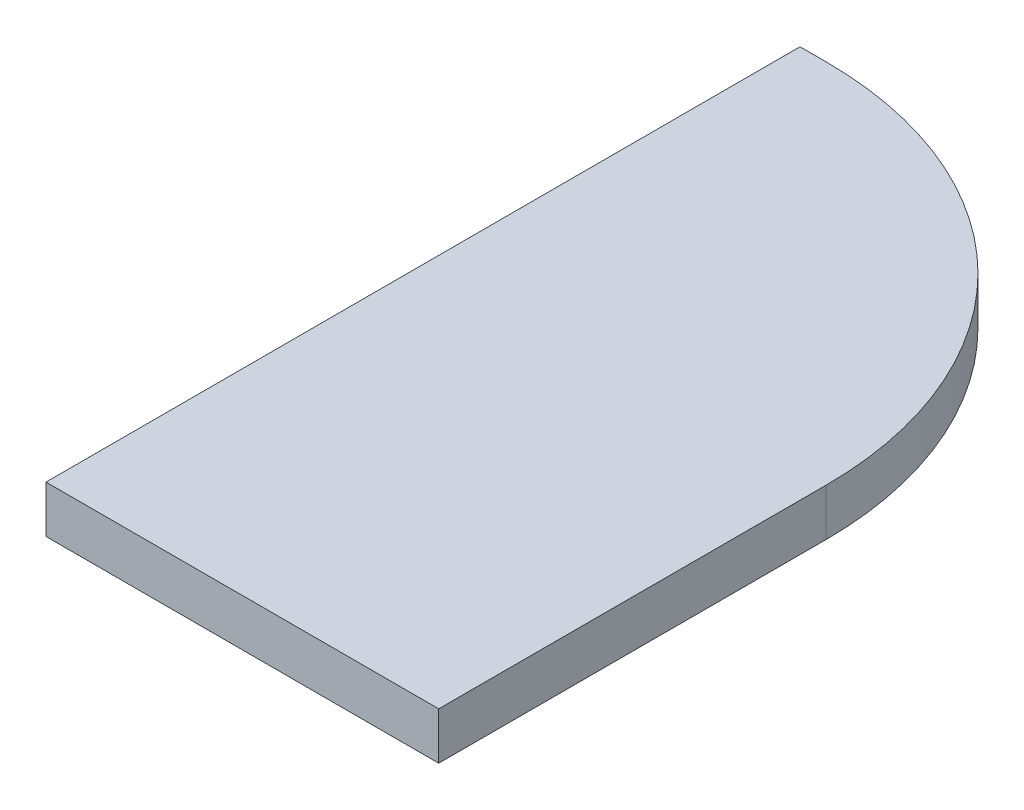
from build123d import *

# Parameters (mm, degrees)
BOSS_EXTRUDE1_DEPTH = 18


with BuildPart() as part:
    # Sketch1 → Boss-Extrude1 (new body)
    with BuildSketch(Plane(origin=(0, 0, 0), x_dir=(1, 0, 0), z_dir=(0, 1, 0))):
        with BuildLine():
            Line((75, -144), (-75, -144))
            Line((-75, -144), (-75, 144))
            Line((-75, 144), (-65, 144))
            ThreePointArc((-65, 144), (33.994949366, 102.994949366), (75, 4))
            Line((75, 4), (75, -144))
        make_face()
    extrude(amount=BOSS_EXTRUDE1_DEPTH)


solid = part.part
